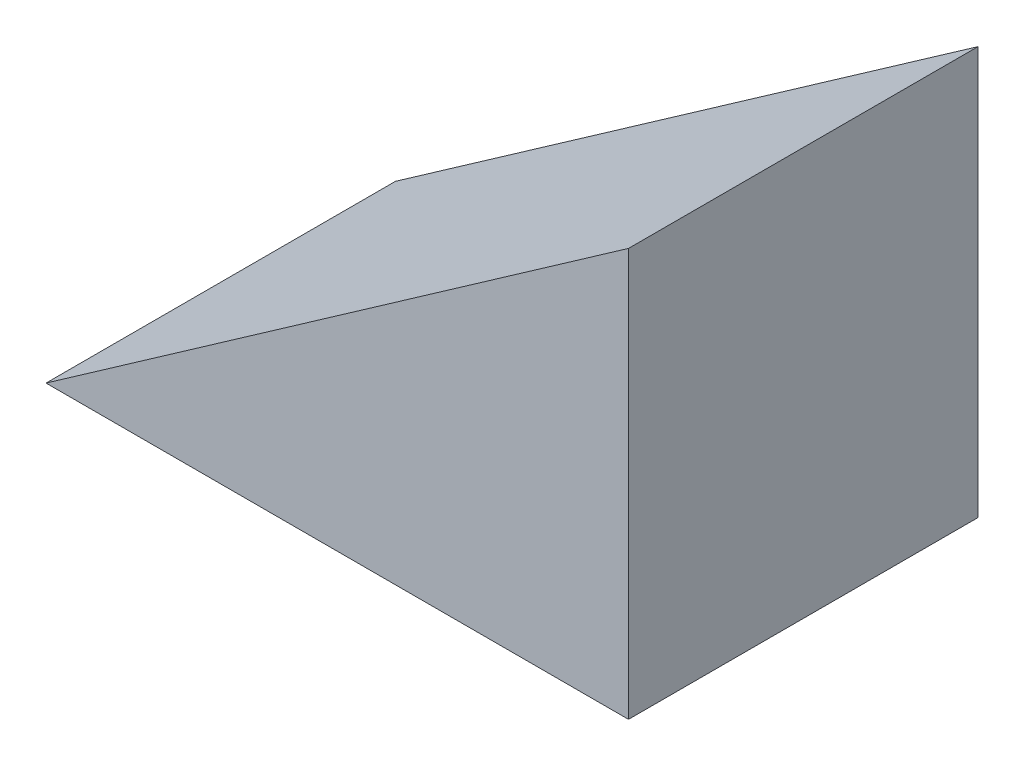
from build123d import *

# Parameters (mm, degrees)
BOSS_EXTRUDE1_DEPTH = 30


with BuildPart() as part:
    # Sketch1 → Boss-Extrude1 (new body)
    with BuildSketch(Plane.XY):
        Polygon((0, 0), (-50, 0), (0, 35.01037691), align=None)
    extrude(amount=BOSS_EXTRUDE1_DEPTH)


solid = part.part
